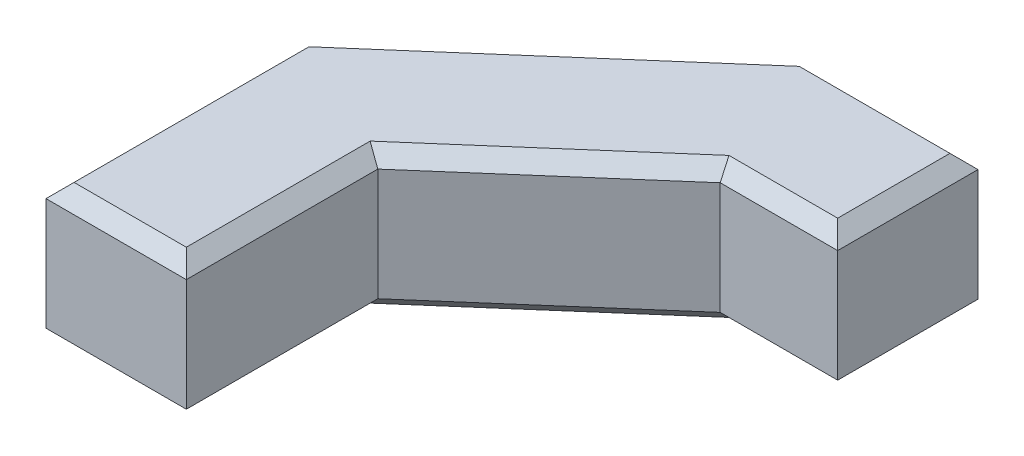
from build123d import *

# Parameters (mm, degrees)
BOSS_EXTRUDE1_DEPTH = 20
CHAMFER1_SIZE       = 2


with BuildPart() as part:
    # Sketch1 → Boss-Extrude1 (new body)
    with BuildSketch(Plane(origin=(0, 0, 0), x_dir=(1, 0, 0), z_dir=(0, 1, 0))):
        Polygon((42.830428459, 91.348139701), (18.601676139, 91.348139701), (-20, 57.741800753), (-20, 21.348139701), (0, 21.348139701), (0, 48.636252059), (26.0878441, 71.348139701), (42.830428459, 71.348139701), align=None)
    extrude(amount=BOSS_EXTRUDE1_DEPTH)

    # Chamfer1
    chamfer1_edges = [part.edges().sort_by_distance(p)[0] for p in [
        (-20, 0, -39.544970227),
        (-0.699161931, 0, -74.544970227),
        (30.716052299, 0, -91.348139701),
        (42.830428459, 0, -81.348139701),
        (-0.699161931, 20, -74.544970227),
        (-20, 20, -39.544970227),
        (-10, 20, -21.348139701),
        (0, 20, -34.99219588),
        (13.04392205, 20, -59.99219588),
        (34.459136279, 20, -71.348139701),
        (42.830428459, 20, -81.348139701),
        (34.459136279, 0, -71.348139701),
        (30.716052299, 20, -91.348139701),
        (13.04392205, 0, -59.99219588),
        (0, 0, -34.99219588),
        (-10, 0, -21.348139701),
    ]]
    chamfer(chamfer1_edges, length=CHAMFER1_SIZE)


solid = part.part
